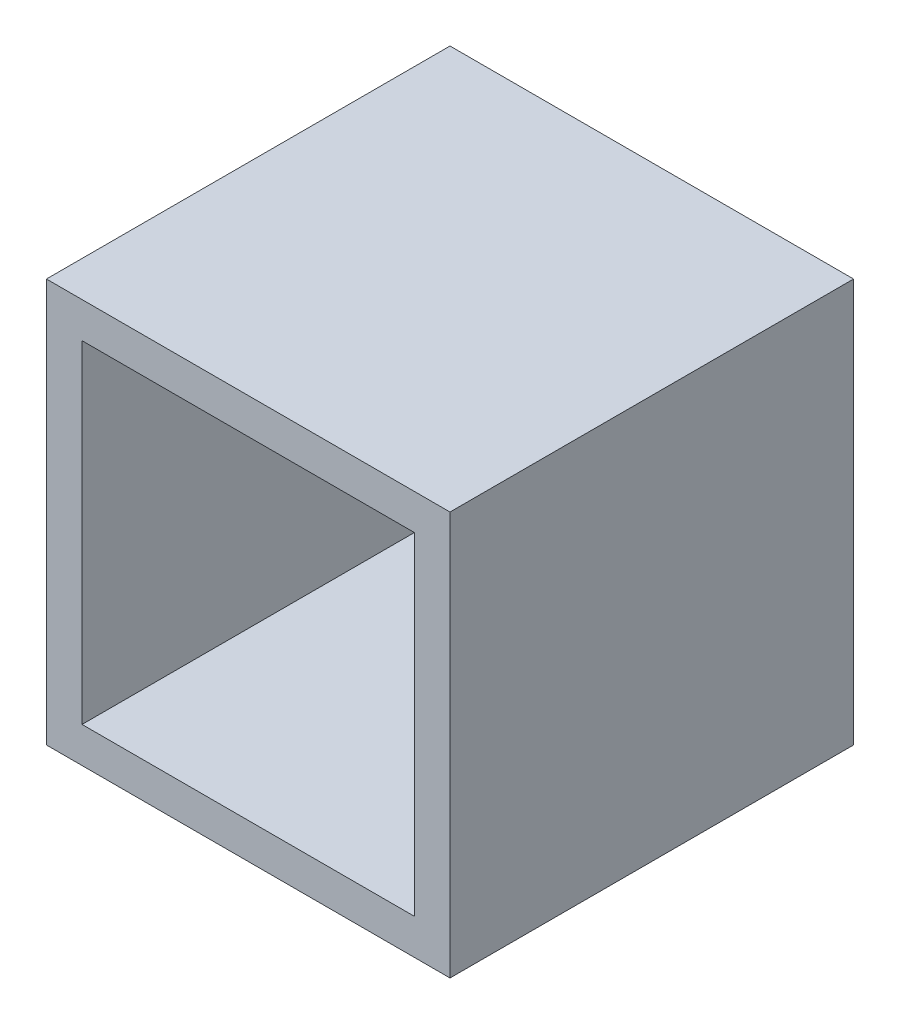
from build123d import *

# Parameters (mm, degrees)
SKETCH_1_W      = 34
SKETCH_1_H      = 34
SKETCH_1_W_2    = 28
SKETCH_1_H_2    = 28
EXTRUDE_1_DEPTH = 34
EXTRUDE_2_REACH = 33
SKETCH_2_W      = 3
SKETCH_2_H      = 28


with BuildPart() as part:
    # 草图1 → 凸台-拉伸1 (new body)
    with BuildSketch(Plane.XY):
        Rectangle(SKETCH_1_W, SKETCH_1_H)
        Rectangle(SKETCH_1_W_2, SKETCH_1_H_2, mode=Mode.SUBTRACT)
    extrude(amount=EXTRUDE_1_DEPTH)

    # 草图2 → 凸台-拉伸2 (add, up to next)
    with BuildSketch(Plane(origin=(-14, 0, 0), x_dir=(0, 0, -1), z_dir=(1, 0, 0)), mode=Mode.PRIVATE) as extrude_2_sk1:
        with Locations((-1.5, 0)):
            Rectangle(SKETCH_2_W, SKETCH_2_H)
    extrude_2_tool1 = extrude(extrude_2_sk1.sketch, amount=EXTRUDE_2_REACH, mode=Mode.PRIVATE) - part.part
    add(extrude_2_tool1.solids().sort_by_distance((-14, 0, 1.5))[0])


solid = part.part
